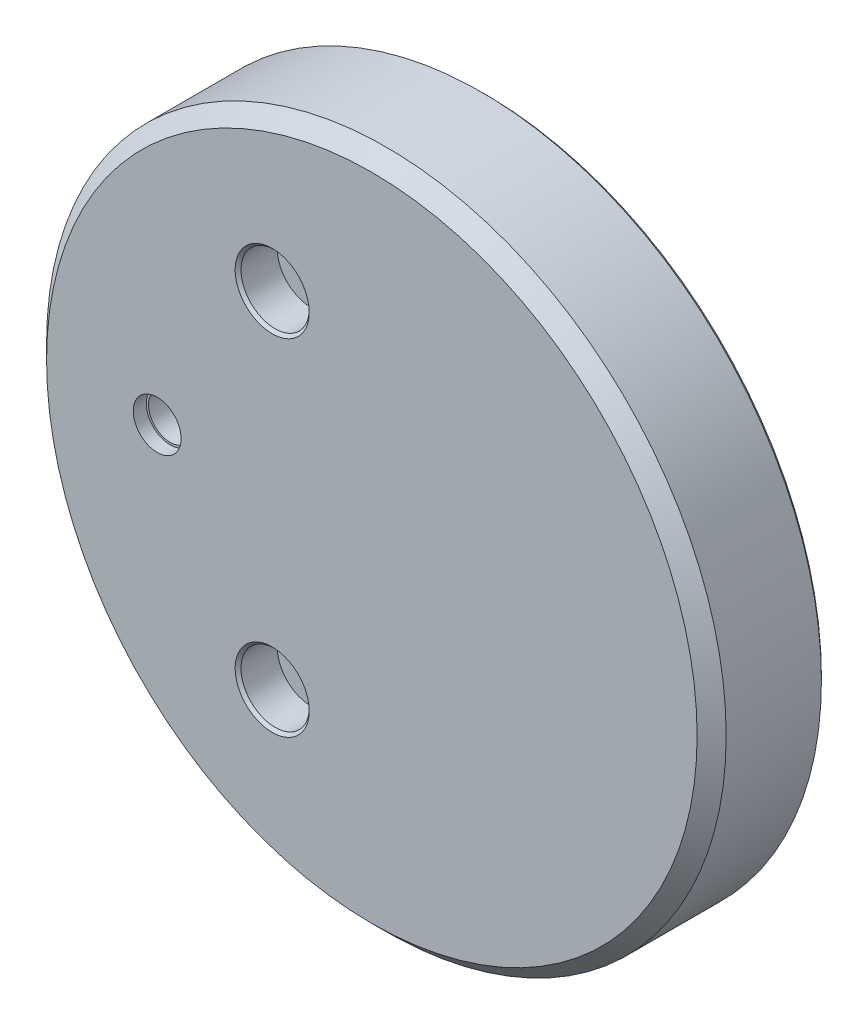
from build123d import *

# Parameters (mm, degrees)
SKETCH_3_R          = 23.4
EXTRUDE_1_DEPTH     = 7.81
SKETCH_2_R          = 21.6
CUT_EXTRUDE_1_DEPTH = 2.1
CUT_EXTRUDE_START   = 2.1
CUT_EXTRUDE_2_DEPTH = 3.2
CUT_EXTRUDE_START_2 = 7.81
SKETCH_4_R          = 1.49999954
SKETCH_4_R_2        = 1.25000004
CUT_EXTRUDE_5_DEPTH = 8.81
SKETCH_5_R          = 1.65
CUT_EXTRUDE_6_DEPTH = 0.9
SKETCH_6_R          = 2.35
CUT_EXTRUDE_7_DEPTH = 2.7
CUT_EXTRUDE_START_3 = 5.3
SKETCH_7_R          = 3.2
CUT_EXTRUDE_8_DEPTH = 1
CHAMFER_1_SIZE      = 1
CHAMFER_2_SIZE      = 0.25
CHAMFER_3_SIZE      = 0.2


with BuildPart() as part:
    # 草图3 → 凸台-拉伸1 (new body)
    with BuildSketch(Plane.XY):
        with Locations((100.000148425, 100.000129687)):
            Circle(SKETCH_3_R)
    extrude(amount=EXTRUDE_1_DEPTH)

    # 草图2 → 切除-拉伸1 (cut)
    with BuildSketch(Plane.XY):
        with Locations((100.000148425, 100.000129687)):
            Circle(SKETCH_2_R)
    extrude(amount=CUT_EXTRUDE_1_DEPTH, mode=Mode.SUBTRACT)

    # 草图1 → 切除-拉伸2 (cut)
    with BuildSketch(Plane.XY.offset(CUT_EXTRUDE_START)):
        with BuildLine():
            Line((112.259115553, 115.826027875), (111.656637713, 115.826027875))
            Line((111.656637713, 115.826027875), (97.599477613, 115.826027875))
            Line((97.599477613, 115.826027875), (96.687659742, 115.826027875))
            ThreePointArc((96.687659742, 115.826027875), (96.087351408, 115.611111205), (95.759847053, 115.064027875))
            Line((95.759847053, 115.064027875), (95.759847053, 109.857027875))
            Line((95.759847053, 109.857027875), (95.759847053, 105.158027875))
            ThreePointArc((95.759847053, 105.158027875), (95.387872666, 104.260002263), (94.489847053, 103.888027875))
            Line((94.489847053, 103.888027875), (83.186847053, 103.888027875))
            ThreePointArc((83.186847053, 103.888027875), (82.288821441, 103.516053487), (81.916847053, 102.618027875))
            Line((81.916847053, 102.618027875), (81.916847053, 92.712027875))
            ThreePointArc((81.916847053, 92.712027875), (82.288821441, 91.814002263), (83.186847053, 91.442027875))
            Line((83.186847053, 91.442027875), (92.965847053, 91.442027875))
            ThreePointArc((92.965847053, 91.442027875), (94.021841281, 91.231977601), (94.917069973, 90.633804955))
            Line((94.917069973, 90.633804955), (95.676425833, 89.874449095))
            ThreePointArc((95.676425833, 89.874449095), (96.208135359, 89.078689918), (96.394847053, 88.140027875))
            Line((96.394847053, 88.140027875), (96.394847053, 81.461633815))
            ThreePointArc((96.394847053, 81.461633815), (96.427853197, 81.29569991), (96.521847053, 81.155027875))
            ThreePointArc((96.521847053, 81.155027875), (96.943861908, 80.87304655), (97.441662377, 80.774027875))
            Line((97.441662377, 80.774027875), (97.537847053, 80.774027875))
            Line((97.537847053, 80.774027875), (101.772425833, 80.774027875))
            Line((101.772425833, 80.774027875), (102.236847053, 80.774027875))
            ThreePointArc((102.236847053, 80.774027875), (102.865464982, 81.034409947), (103.125847053, 81.663027875))
            Line((103.125847053, 81.663027875), (103.125847053, 83.695027875))
            ThreePointArc((103.125847053, 83.695027875), (103.349031686, 84.233843243), (103.887847053, 84.457027875))
            Line((103.887847053, 84.457027875), (111.60403053, 84.457027875))
            ThreePointArc((111.60403053, 84.457027875), (112.336497489, 84.602724612), (112.957452993, 85.017633815))
            Line((112.957452993, 85.017633815), (117.811624454, 89.871805276))
            ThreePointArc((117.811624454, 89.871805276), (118.408450098, 90.766392606), (118.618000745, 91.821179725))
            Line((118.618000745, 91.821179725), (118.618000745, 108.839))
            Line((118.618000745, 108.839), (118.618000745, 109.460547459))
            ThreePointArc((118.618000745, 109.460547459), (118.537945969, 109.810671539), (118.33936792, 110.109941312))
            Line((118.33936792, 110.109941312), (117.729, 110.744000093))
            Line((117.729, 110.744000093), (115.585546543, 112.887726165))
            ThreePointArc((115.585546543, 112.887726165), (114.325244429, 114.275507158), (112.941853583, 115.540626625))
            ThreePointArc((112.941853583, 115.540626625), (112.628834267, 115.751145515), (112.259115553, 115.826027875))
        make_face()
    extrude(amount=CUT_EXTRUDE_2_DEPTH, mode=Mode.SUBTRACT)

    # 草图4 → 切除-拉伸5 (cut, through all)
    with BuildSketch(Plane.XY.offset(CUT_EXTRUDE_START_2)):
        with Locations((85.217, 99.949)):
            Circle(SKETCH_4_R)
        with Locations((93.13750232, 88.11380142)):
            Circle(SKETCH_4_R_2)
        with Locations((93.13749978, 111.8861999)):
            Circle(SKETCH_4_R_2)
    extrude(amount=-CUT_EXTRUDE_5_DEPTH, mode=Mode.SUBTRACT)

    # 草图5 → 切除-拉伸6 (cut)
    with BuildSketch(Plane.XY.offset(CUT_EXTRUDE_START_2)):
        with Locations((85.217, 99.949)):
            Circle(SKETCH_5_R)
    extrude(amount=-CUT_EXTRUDE_6_DEPTH, mode=Mode.SUBTRACT)

    # 草图6 → 切除-拉伸7 (cut)
    with BuildSketch(Plane.XY.offset(CUT_EXTRUDE_START_2)):
        with Locations((93.13749978, 111.8861999)):
            Circle(SKETCH_6_R)
        with Locations((93.13750232, 88.11380142)):
            Circle(SKETCH_6_R)
    extrude(amount=-CUT_EXTRUDE_7_DEPTH, mode=Mode.SUBTRACT)

    # 草图7 → 切除-拉伸8 (cut)
    with BuildSketch(Plane.XY.offset(CUT_EXTRUDE_START_3)):
        with Locations((100.018718989, 99.944811263)):
            Circle(SKETCH_7_R)
    extrude(amount=CUT_EXTRUDE_8_DEPTH, mode=Mode.SUBTRACT)

    # 倒角1
    chamfer_1_edges = [part.edges().sort_by_distance(p)[0] for p in [
        (76.600148425, 100.000129687, 7.81),
    ]]
    chamfer(chamfer_1_edges, length=CHAMFER_1_SIZE)

    # 倒角2
    chamfer_2_edges = [part.edges().sort_by_distance(p)[0] for p in [
        (76.600148425, 100.000129687, 0),
        (78.400148425, 100.000129687, 0),
    ]]
    chamfer(chamfer_2_edges, length=CHAMFER_2_SIZE)

    # 倒角3
    chamfer_3_edges = [part.edges().sort_by_distance(p)[0] for p in [
        (90.78749978, 111.8861999, 7.81),
        (90.78750232, 88.11380142, 7.81),
        (96.818718989, 99.944811263, 5.3),
    ]]
    chamfer(chamfer_3_edges, length=CHAMFER_3_SIZE)


solid = part.part
